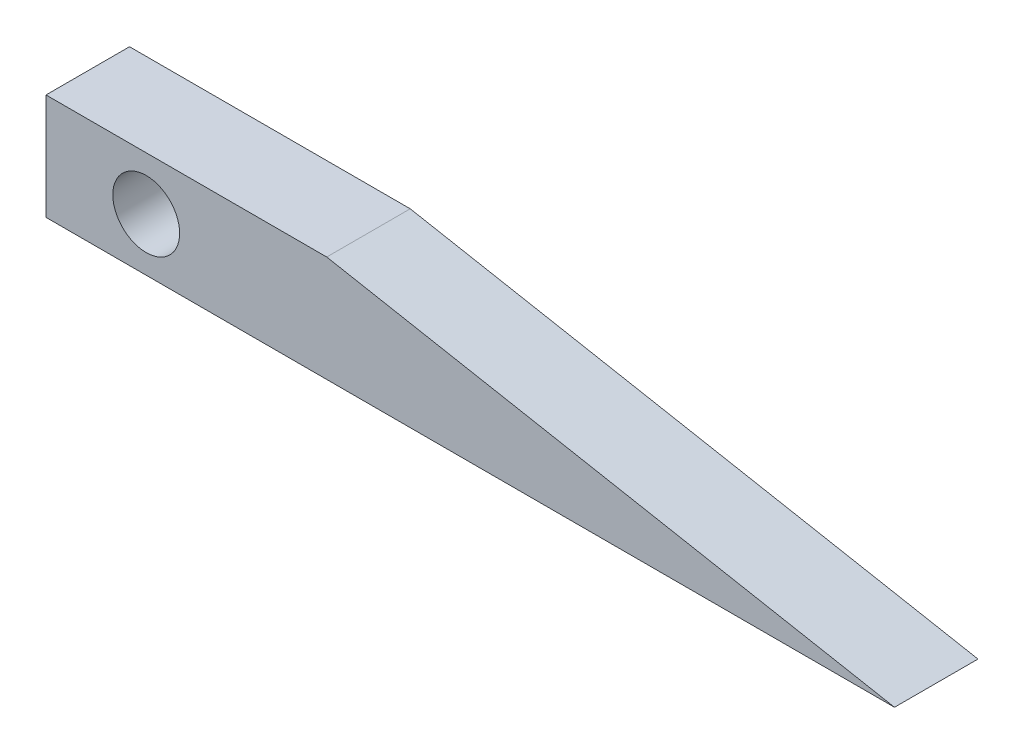
from build123d import *

# Parameters (mm, degrees)
SKETCH1_W           = 50.8
SKETCH1_H           = 6.35
BOSS_EXTRUDE1_DEPTH = 5
SKETCH2_R           = 2
CUT_EXTRUDE1_DEPTH  = 5
CUT_EXTRUDE2_DEPTH  = 5


with BuildPart() as part:
    # Sketch1 → Boss-Extrude1 (new body)
    with BuildSketch(Plane.XY):
        with Locations((25.4, 3.175)):
            Rectangle(SKETCH1_W, SKETCH1_H)
    extrude(amount=BOSS_EXTRUDE1_DEPTH)

    # Sketch2 → Cut-Extrude1 (cut)
    with BuildSketch(Plane(origin=(0, 0, 0), x_dir=(-1, 0, 0), z_dir=(0, 0, -1))):
        with Locations((-6, 3.175)):
            Circle(SKETCH2_R)
    extrude(amount=-CUT_EXTRUDE1_DEPTH, mode=Mode.SUBTRACT)

    # Sketch3 → Cut-Extrude2 (cut)
    with BuildSketch(Plane(origin=(0, 0, 0), x_dir=(-1, 0, 0), z_dir=(0, 0, -1))):
        Polygon((-50.8, 0), (-16.807033998, 6.35), (-50.8, 6.35), align=None)
    extrude(amount=-CUT_EXTRUDE2_DEPTH, mode=Mode.SUBTRACT)


solid = part.part
